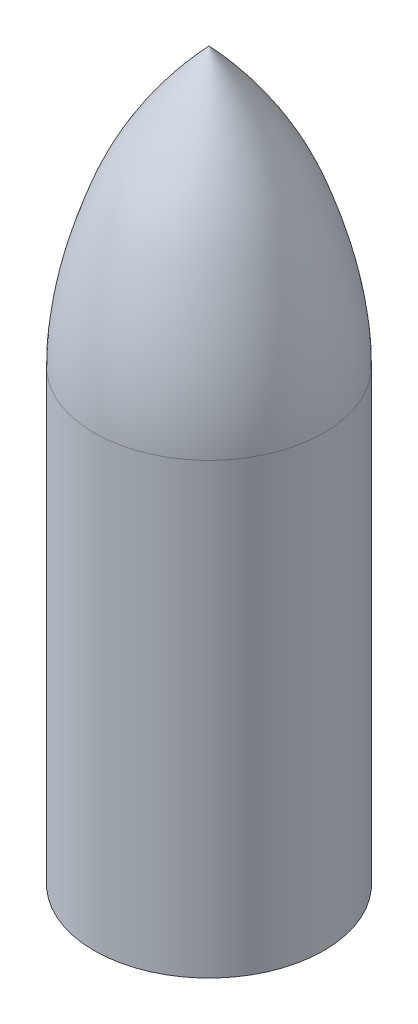
from build123d import *

# Parameters (mm, degrees)
BOSS_EXTRUDE1_DEPTH = 160


with BuildPart() as part:
    # Sketch1 → Boss-Extrude1 (new body)
    with BuildSketch(Plane(origin=(0, 0, 0), x_dir=(1, 0, 0), z_dir=(0, 1, 0))):
        with BuildLine():
            ThreePointArc((41, 0), (40.739454279, 4.61485266), (39.961128533, 9.171052632))
            Line((39.961128533, 9.171052632), (37.026014985, 9.171052632))
            Line((37.026014985, 9.171052632), (37.026014985, 0))
            Line((37.026014985, 0), (41, 0))
        make_face()
        with BuildLine():
            ThreePointArc((39.961128533, -9.171052632), (40.739454279, -4.61485266), (41, 0))
            Line((41, 0), (37.026014985, 0))
            Line((37.026014985, 0), (37.026014985, -9.171052632))
            Line((37.026014985, -9.171052632), (39.961128533, -9.171052632))
        make_face()
        with BuildLine():
            Line((-36.973985015, 0), (-41, 0))
            ThreePointArc((-41, 0), (-40.739454279, -4.61485266), (-39.961128533, -9.171052632))
            Line((-39.961128533, -9.171052632), (-36.973985015, -9.171052632))
            Line((-36.973985015, -9.171052632), (-36.973985015, 0))
        make_face()
        with BuildLine():
            Line((-25.394719798, -9.171052632), (-36.973985015, -9.171052632))
            Line((-36.973985015, -9.171052632), (-36.973985015, -17.717912748))
            ThreePointArc((-36.973985015, -17.717912748), (4.526915182, -40.74931949), (39.961128533, -9.171052632))
            Line((39.961128533, -9.171052632), (37.026014985, -9.171052632))
            Line((37.026014985, -9.171052632), (25.394719798, -9.171052632))
            ThreePointArc((25.394719798, -9.171052632), (0, -27), (-25.394719798, -9.171052632))
        make_face()
        with BuildLine():
            Line((-36.973985015, 9.171052632), (-39.961128533, 9.171052632))
            ThreePointArc((-39.961128533, 9.171052632), (-40.739454279, 4.61485266), (-41, 0))
            Line((-41, 0), (-36.973985015, 0))
            Line((-36.973985015, 0), (-36.973985015, 9.171052632))
        make_face()
        with BuildLine():
            ThreePointArc((39.961128533, 9.171052632), (0, 41), (-39.961128533, 9.171052632))
            Line((-39.961128533, 9.171052632), (-36.973985015, 9.171052632))
            Line((-36.973985015, 9.171052632), (-25.394719798, 9.171052632))
            ThreePointArc((-25.394719798, 9.171052632), (0, 27), (25.394719798, 9.171052632))
            Line((25.394719798, 9.171052632), (37.026014985, 9.171052632))
            Line((37.026014985, 9.171052632), (39.961128533, 9.171052632))
        make_face()
        with BuildLine():
            Line((-36.973985015, -9.171052632), (-39.961128533, -9.171052632))
            ThreePointArc((-39.961128533, -9.171052632), (-38.7042004, -13.527190078), (-36.973985015, -17.717912748))
            Line((-36.973985015, -17.717912748), (-36.973985015, -9.171052632))
        make_face()
    extrude(amount=-BOSS_EXTRUDE1_DEPTH)

    # Sketch2 → Revolve1 (revolve)
    with BuildSketch(Plane.XY):
        with BuildLine():
            Line((0, 0), (0, 99.064623465))
            add(Edge.make_bspline(
                [(0, 99.064623465), (11.435717322, 87.036046157), (23.647174069, 70.328206009), (36.388082529, 36.329625432), (40.969226805, 16.559428814), (41, 0)],
                knots=[0, 0, 0, 0, 0.458505426, 0.547537698, 1, 1, 1, 1], degree=3))
            Line((41, 0), (0, 0))
        make_face()
    revolve(axis=Axis((0, 0, 0), (0, 1, 0)))


solid = part.part
